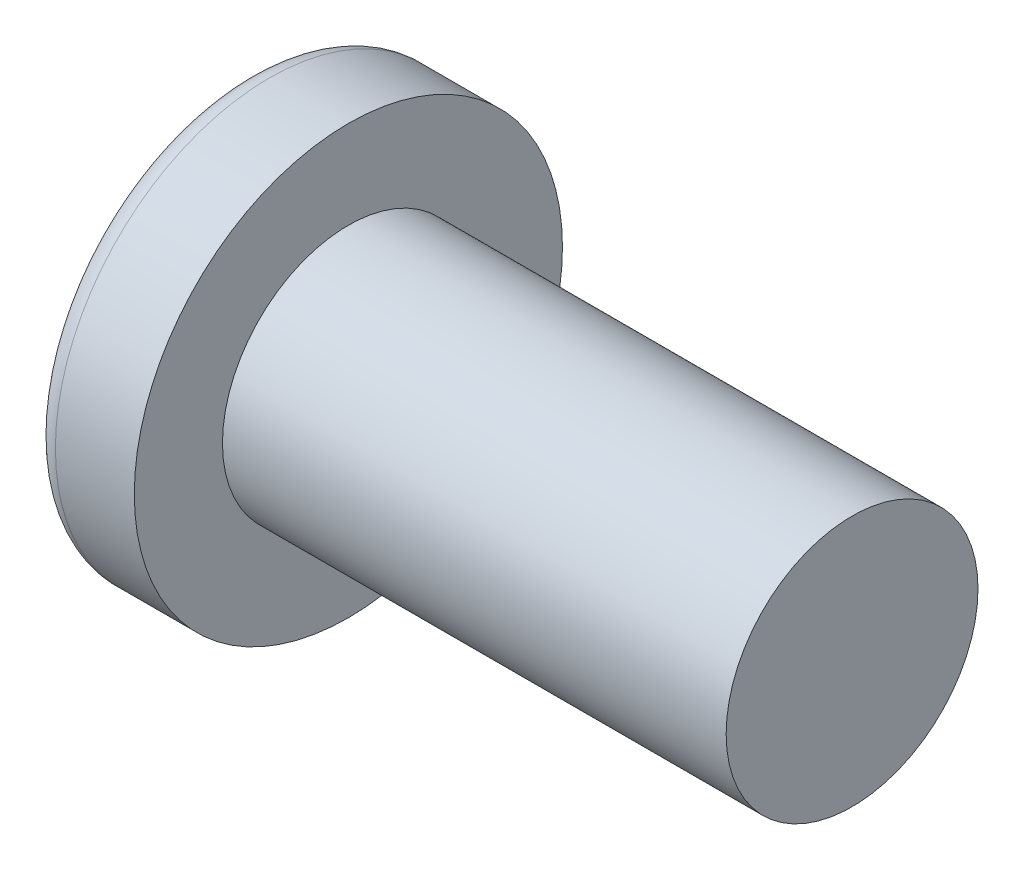
from build123d import *


with BuildPart() as part:
    # Çizim1 → Döndür1 (revolve)
    with BuildSketch(Plane(origin=(0, 0, 0), x_dir=(1, 0, 0), z_dir=(0, 1, 0))):
        with BuildLine():
            Line((-7.8, 0), (0, 0))
            Line((0, 0), (0, 1.5))
            Line((0, 1.5), (-6, 1.5))
            Line((-6, 1.5), (-6, 2.55))
            Line((-6, 2.55), (-6.94, 2.55))
            ThreePointArc((-6.94, 2.55), (-7.104337344, 2.49422707), (-7.200781538, 2.349949907))
            ThreePointArc((-7.200781538, 2.349949907), (-7.661172102, 1.21597291), (-7.8, 0))
        make_face()
    revolve(axis=Axis((-7.8, 0, 0), (1, 0, 0)))


solid = part.part
